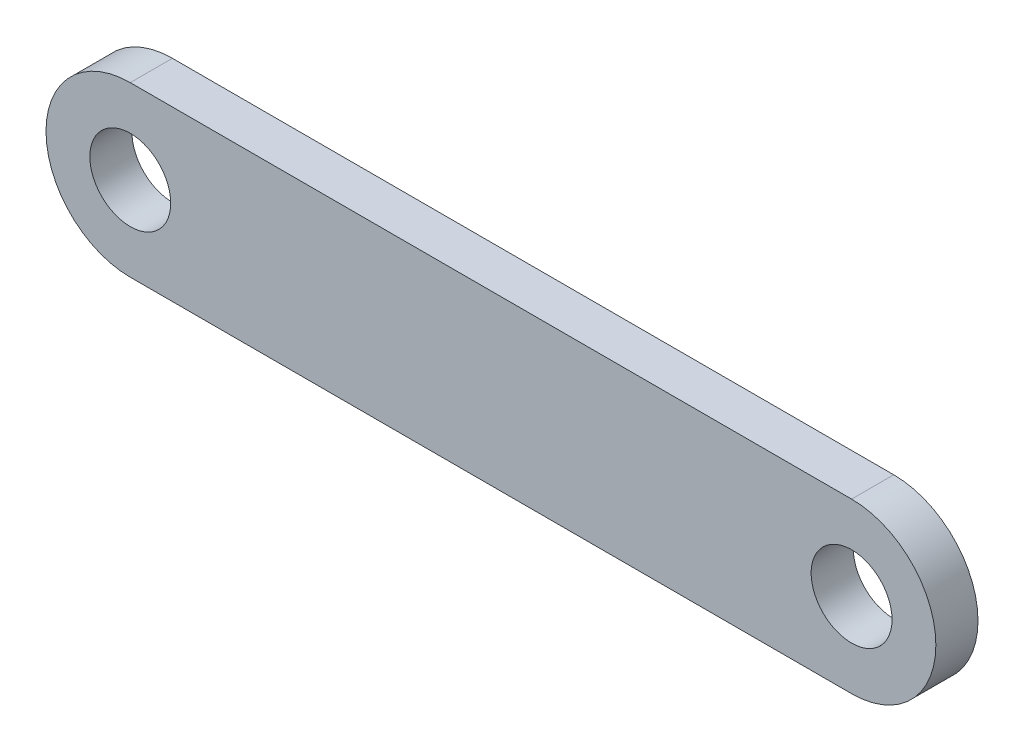
from build123d import *

# Parameters (mm, degrees)
SKETCH1_R           = 3.048
BOSS_EXTRUDE1_DEPTH = 3.175


with BuildPart() as part:
    # Sketch1 → Boss-Extrude1 (new body)
    with BuildSketch(Plane.XY):
        with BuildLine():
            Line((-27.178, -6.35), (27.178, -6.35))
            ThreePointArc((27.178, -6.35), (33.528, 0), (27.178, 6.35))
            Line((27.178, 6.35), (-27.178, 6.35))
            ThreePointArc((-27.178, 6.35), (-33.528, 0), (-27.178, -6.35))
        make_face()
        with Locations((27.178, 0)):
            Circle(SKETCH1_R, mode=Mode.SUBTRACT)
        with Locations((-27.178, 0)):
            Circle(SKETCH1_R, mode=Mode.SUBTRACT)
    extrude(amount=BOSS_EXTRUDE1_DEPTH)


solid = part.part
